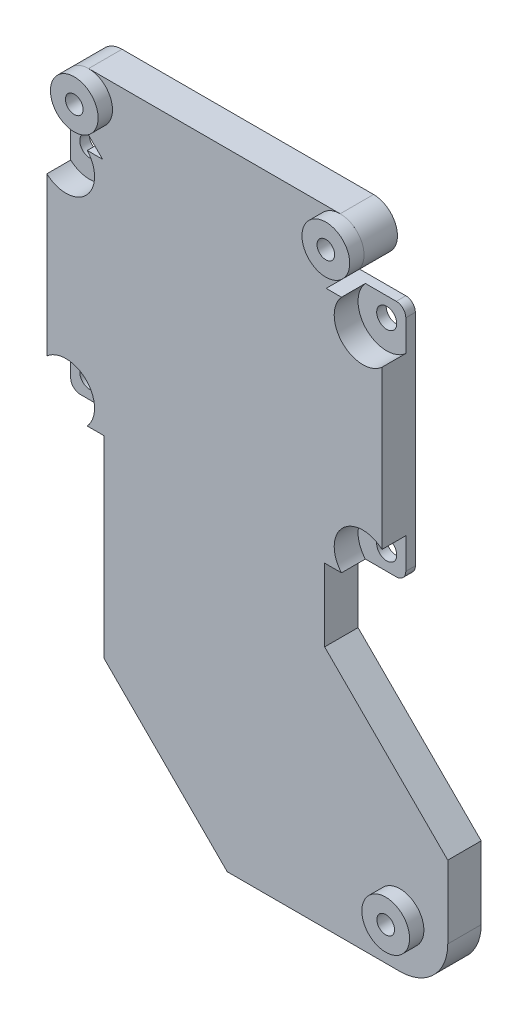
from build123d import *

# Parameters (mm, degrees)
SKETCH1_R             = 2.1
BOSS_EXTRUDE1_DEPTH   = 2
BOSS_EXTRUDE2_DEPTH   = 5
SKETCH3_R             = 5
SKETCH3_R_2           = 1.85
BOSS_EXTRUDE3_DEPTH   = 3
BOSS_EXTRUDE3_2_DEPTH = 3
BOSS_EXTRUDE3_3_DEPTH = 3
SKETCH4_R             = 1.85
BOSS_EXTRUDE4_DEPTH   = 7


with BuildPart() as part:
    # Sketch1 → Boss-Extrude1 (new body)
    with BuildSketch(Plane.XY):
        with BuildLine():
            Line((-68.2, 50), (-2, 50))
            ThreePointArc((-2, 50), (-0.585786438, 49.414213562), (0, 48))
            Line((0, 48), (0, 2))
            ThreePointArc((0, 2), (-0.585786438, 0.585786438), (-2, 0))
            Line((-2, 0), (-68.2, 0))
            ThreePointArc((-68.2, 0), (-69.614213562, 0.585786438), (-70.2, 2))
            Line((-70.2, 2), (-70.2, 48))
            ThreePointArc((-70.2, 48), (-69.614213562, 49.414213562), (-68.2, 50))
        make_face()
        with Locations((-66.2, 46)):
            Circle(SKETCH1_R, mode=Mode.SUBTRACT)
        with Locations((-4, 46)):
            Circle(SKETCH1_R, mode=Mode.SUBTRACT)
        with Locations((-4, 4)):
            Circle(SKETCH1_R, mode=Mode.SUBTRACT)
        with Locations((-66.2, 4)):
            Circle(SKETCH1_R, mode=Mode.SUBTRACT)
    extrude(amount=BOSS_EXTRUDE1_DEPTH)

    # Sketch2 → Boss-Extrude2 (add)
    with BuildSketch(Plane.XY.offset(2)):
        with BuildLine():
            Line((-61.727864045, 0), (-8.472135955, 0))
            ThreePointArc((-8.472135955, 0), (-8.242640687, 8.242640687), (0, 8.472135955))
            Line((0, 8.472135955), (0, 41.527864045))
            ThreePointArc((0, 41.527864045), (-8.242640687, 41.757359313), (-8.472135955, 50))
            Line((-8.472135955, 50), (-61.727864045, 50))
            ThreePointArc((-61.727864045, 50), (-61.957359313, 41.757359313), (-70.2, 41.527864045))
            Line((-70.2, 41.527864045), (-70.2, 8.472135955))
            ThreePointArc((-70.2, 8.472135955), (-61.957359313, 8.242640687), (-61.727864045, 0))
        make_face()
    extrude(amount=BOSS_EXTRUDE2_DEPTH)



with BuildPart() as body_2:
    # Sketch3 → Boss-Extrude3 (new body)
    with BuildSketch(Plane.XY.offset(7)):
        with Locations((-61.45, 60)):
            Circle(SKETCH3_R)
        with Locations((-61.45, 60)):
            Circle(SKETCH3_R_2, mode=Mode.SUBTRACT)
    extrude(amount=BOSS_EXTRUDE3_DEPTH)


with BuildPart() as body_3:
    # Sketch3 → Boss-Extrude3 2 (new body)
    with BuildSketch(Plane.XY.offset(7)):
        with Locations((-8.75, 60)):
            Circle(SKETCH3_R)
        with Locations((-8.75, 60)):
            Circle(SKETCH3_R_2, mode=Mode.SUBTRACT)
    extrude(amount=BOSS_EXTRUDE3_2_DEPTH)


with BuildPart() as body_4:
    # Sketch3 → Boss-Extrude3 3 (new body)
    with BuildSketch(Plane.XY.offset(7)):
        with Locations((3.79, -56.2)):
            Circle(SKETCH3_R)
        with Locations((3.79, -56.2)):
            Circle(SKETCH3_R_2, mode=Mode.SUBTRACT)
    extrude(amount=BOSS_EXTRUDE3_3_DEPTH)


with BuildPart() as part_1:
    add(part.part)

    add(body_4.part)  # Boss-Extrude4 merges body 4
    # Sketch4 → Boss-Extrude4 (add)
    with BuildSketch(Plane.XY.offset(7)):
        with BuildLine():
            Line((13.79, -56.2), (13.79, -40.995))
            Line((13.79, -40.995), (-12, -15.205))
            Line((-12, -15.205), (-12, 0))
            Line((-12, 0), (-58.2, 0))
            Line((-58.2, 0), (-58.2, -40.41))
            Line((-58.2, -40.41), (-32.41, -66.2))
            Line((-32.41, -66.2), (3.79, -66.2))
            ThreePointArc((3.79, -66.2), (10.861067812, -63.271067812), (13.79, -56.2))
        make_face()
        with Locations((3.79, -56.2)):
            Circle(SKETCH4_R, mode=Mode.SUBTRACT)
        with BuildLine():
            Line((-64.985533906, 56.464466094), (-58.521067812, 50))
            Line((-58.521067812, 50), (-11.678932188, 50))
            Line((-11.678932188, 50), (-5.214466094, 56.464466094))
            ThreePointArc((-5.214466094, 56.464466094), (-4.130602337, 61.913417162), (-8.75, 65))
            Line((-8.75, 65), (-61.45, 65))
            ThreePointArc((-61.45, 65), (-66.069397663, 61.913417162), (-64.985533906, 56.464466094))
        make_face()
        with Locations((-61.45, 60)):
            Circle(SKETCH4_R, mode=Mode.SUBTRACT)
        with Locations((-8.75, 60)):
            Circle(SKETCH4_R, mode=Mode.SUBTRACT)
    extrude(amount=-BOSS_EXTRUDE4_DEPTH)


solid = Compound([body_2.part, body_3.part, part_1.part])
